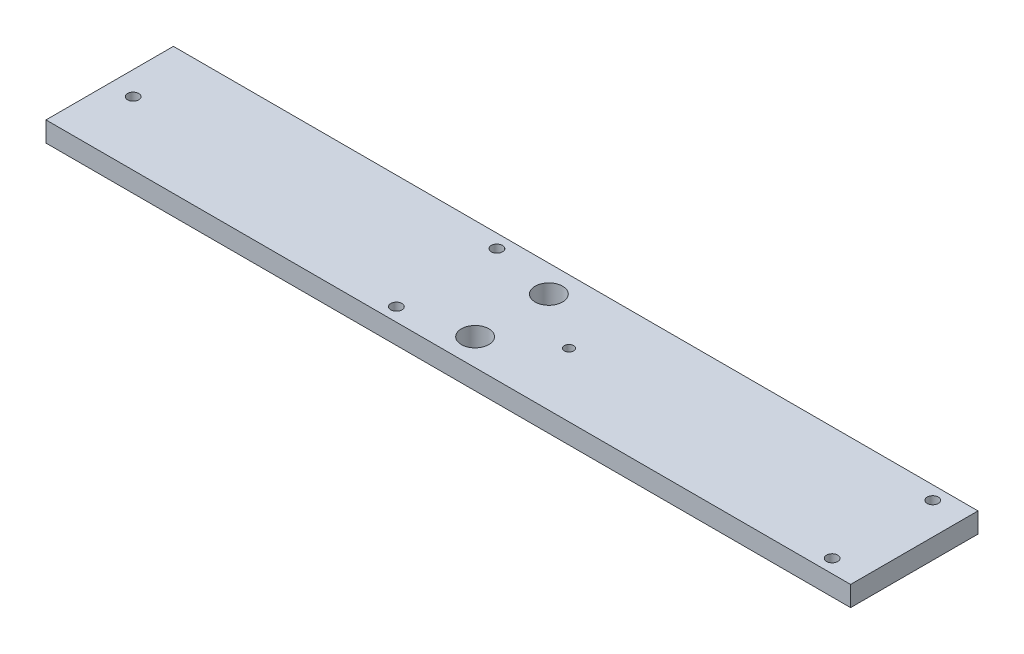
from build123d import *

# Parameters (mm, degrees)
SKETCH1_W           = 120
SKETCH1_H           = 19
BOSS_EXTRUDE1_DEPTH = 3
SKETCH2_R           = 0.835
SKETCH2_R_2         = 0.69425601
SKETCH2_R_3         = 2.05
CUT_EXTRUDE1_DEPTH  = 4


with BuildPart() as part:
    # Sketch1 → Boss-Extrude1 (new body)
    with BuildSketch(Plane(origin=(0, 0, 0), x_dir=(1, 0, 0), z_dir=(0, 1, 0))):
        with Locations((60, 9.5)):
            Rectangle(SKETCH1_W, SKETCH1_H)
    extrude(amount=BOSS_EXTRUDE1_DEPTH)

    # Sketch2 → Cut-Extrude1 (cut, through all)
    with BuildSketch(Plane(origin=(0, 3, 0), x_dir=(1, 0, 0), z_dir=(0, 1, 0))):
        with Locations((3.5, 9.5)):
            Circle(SKETCH2_R)
        with Locations((50.25, 17)):
            Circle(SKETCH2_R)
        with Locations((50.25, 2)):
            Circle(SKETCH2_R)
        with Locations((68.5, 9.5)):
            Circle(SKETCH2_R_2)
        with Locations((115.25, 17)):
            Circle(SKETCH2_R)
        with Locations((115.25, 2)):
            Circle(SKETCH2_R)
        with Locations((60, 15)):
            Circle(SKETCH2_R_3)
        with Locations((60, 4)):
            Circle(SKETCH2_R_3)
    extrude(amount=-CUT_EXTRUDE1_DEPTH, mode=Mode.SUBTRACT)


solid = part.part
